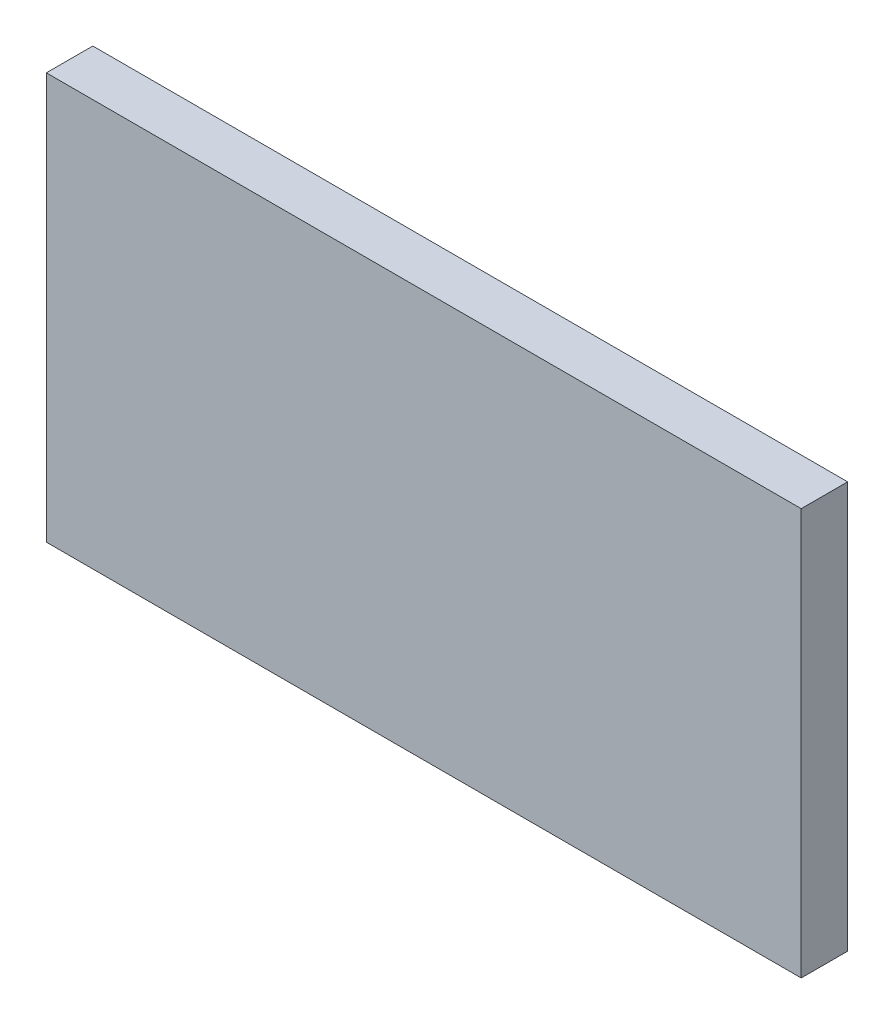
from build123d import *

# Parameters (mm, degrees)
SKETCH1_W           = 130
SKETCH1_H           = 70
BOSS_EXTRUDE1_DEPTH = 8


with BuildPart() as part:
    # Sketch1 → Boss-Extrude1 (new body)
    with BuildSketch(Plane.XY):
        Rectangle(SKETCH1_W, SKETCH1_H)
    extrude(amount=BOSS_EXTRUDE1_DEPTH)


solid = part.part
